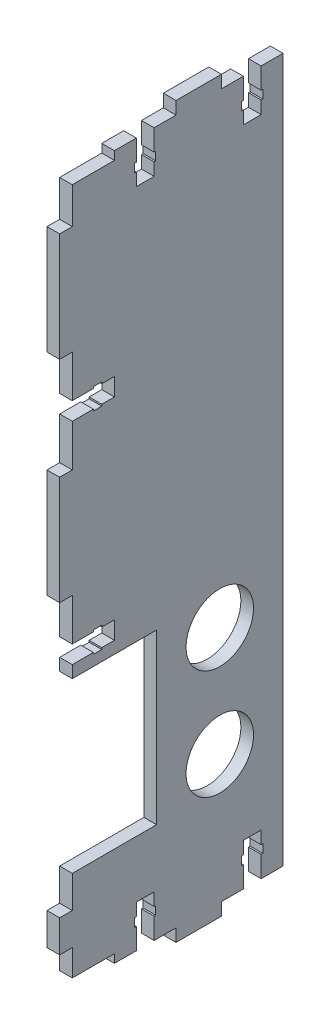
from build123d import *

# Parameters (mm, degrees)
BOSS_EXTRUDE1_DEPTH = 3
SKETCH2_W           = 10
SKETCH2_H           = 2
CUT_EXTRUDE1_DEPTH  = 3
BOSS_EXTRUDE3_DEPTH = 3
SKETCH4_W           = 10
SKETCH4_H           = 2
CUT_EXTRUDE2_DEPTH  = 4
SKETCH5_R           = 8
CUT_EXTRUDE3_DEPTH  = 10


with BuildPart() as part:
    # Sketch1 → Boss-Extrude1 (new body)
    with BuildSketch(Plane(origin=(0, 0, 0), x_dir=(0, 0, -1), z_dir=(1, 0, 0))):
        Polygon((-3, 80.61), (-3, 106.39), (0, 106.39), (0, 113.14), (0, 116.39), (5, 116.39), (5, 116), (7, 116), (7, 116.39), (10, 116.39), (10, 120.61), (7, 120.61), (7, 121), (5, 121), (5, 120.61), (0, 120.61), (0, 124.11), (0, 130.61), (-3, 130.61), (-3, 156.39), (0, 156.39), (0, 159.89), (5, 159.89), (5, 159.5), (7, 159.5), (7, 159.89), (10, 159.89), (10, 164.11), (7, 164.11), (7, 164.5), (5, 164.5), (5, 164.11), (0, 164.11), (0, 167), (15.195, 167), (15.195, 162), (14.805, 162), (14.805, 160), (15.195, 160), (15.195, 157), (19.415, 157), (19.415, 160), (19.805, 160), (19.805, 162), (19.415, 162), (19.415, 167), (24.61, 167), (24.61, 170), (35.39, 170), (35.39, 167), (40.585, 167), (40.585, 162), (40.195, 162), (40.195, 160), (40.585, 160), (40.585, 157), (44.805, 157), (44.805, 160), (45.195, 160), (45.195, 162), (44.805, 162), (44.805, 167), (50, 167), (50, 0), (44.805, 0), (44.805, 5), (45.195, 5), (45.195, 7), (44.805, 7), (44.805, 10), (40.585, 10), (40.585, 7), (40.195, 7), (40.195, 5), (40.585, 5), (40.585, 0), (35.39, 0), (35.39, -3), (24.61, -3), (24.61, 0), (19.415, 0), (19.415, 5), (19.805, 5), (19.805, 7), (19.415, 7), (19.415, 10), (15.195, 10), (15.195, 7), (14.805, 7), (14.805, 5), (15.195, 5), (15.195, 0), (0, 0), (0, 8.24), (-3, 8.24), (-3, 15.87), (0, 15.87), (0, 23.5), (20, 23.5), (20, 63.5), (0, 63.5), (0, 66.39), (5, 66.39), (5, 66), (7, 66), (7, 66.39), (10, 66.39), (10, 70.61), (7, 70.61), (7, 71), (5, 71), (5, 70.61), (0, 70.61), (0, 80.61), align=None)
    extrude(amount=BOSS_EXTRUDE1_DEPTH)

    # Sketch2 → Cut-Extrude1 (cut)
    with BuildSketch(Plane(origin=(3, 0, 0), x_dir=(0, 0, -1), z_dir=(1, 0, 0))):
        with Locations((5, 1)):
            Rectangle(SKETCH2_W, SKETCH2_H)
    extrude(amount=-CUT_EXTRUDE1_DEPTH, mode=Mode.SUBTRACT)

    # Sketch3 → Boss-Extrude3 (add, through all)
    with BuildSketch(Plane(origin=(3, 0, 0), x_dir=(0, 0, -1), z_dir=(1, 0, 0))):
        Polygon((0, 164.11), (0, 159.89), (5, 159.89), (5, 159.5), (7, 159.5), (7, 159.89), (10, 159.89), (10, 164.11), (7, 164.11), (7, 164.5), (5, 164.5), (5, 164.11), align=None)
    extrude(amount=-BOSS_EXTRUDE3_DEPTH)

    # Sketch4 → Cut-Extrude2 (cut, through all)
    with BuildSketch(Plane(origin=(3, 0, 0), x_dir=(0, 0, -1), z_dir=(1, 0, 0))):
        with Locations((5, 166)):
            Rectangle(SKETCH4_W, SKETCH4_H)
    extrude(amount=-CUT_EXTRUDE2_DEPTH, mode=Mode.SUBTRACT)

    # Sketch5 → Cut-Extrude3 (cut)
    with BuildSketch(Plane(origin=(3, 0, 0), x_dir=(0, 0, -1), z_dir=(1, 0, 0))):
        with Locations((35, 30.5)):
            Circle(SKETCH5_R)
        with Locations((35, 56.5)):
            Circle(SKETCH5_R)
    extrude(amount=-CUT_EXTRUDE3_DEPTH, mode=Mode.SUBTRACT)


solid = part.part
